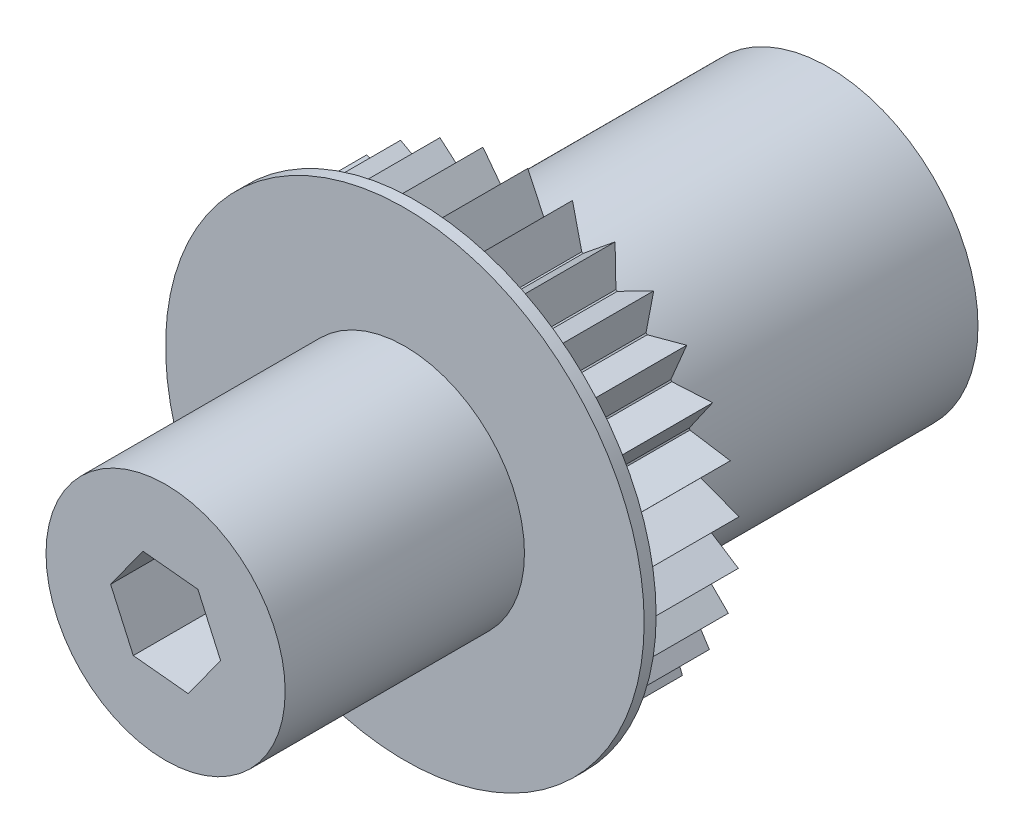
from build123d import *

# Parameters (mm, degrees)
SKETCH1_R               = 12.5
BOSS_EXTRUDE1_DEPTH     = 25.4
SKETCH2_R               = 9.9949
BOSS_EXTRUDE2_DEPTH     = 30
SKETCH4_R               = 15
BOSS_EXTRUDE3_DEPTH     = 10
SKETCH5_R               = 20
BOSS_EXTRUDE4_DEPTH     = 1
CUT_EXTRUDE1_DEPTH      = 1
CUT_EXTRUDE1_DEPTH_BACK = 56.4
CHAMFER1_SIZE           = 3


with BuildPart() as part:
    # Sketch1 → Boss-Extrude1 (new body)
    with BuildSketch(Plane.XY):
        Circle(SKETCH1_R)
    extrude(amount=BOSS_EXTRUDE1_DEPTH)

    # Sketch2 → Boss-Extrude2 (add)
    with BuildSketch(Plane.XY.offset(25.4)):
        Circle(SKETCH2_R)
    extrude(amount=BOSS_EXTRUDE2_DEPTH)

    # Sketch4 → Boss-Extrude3 (add)
    with BuildSketch(Plane.XY.offset(25.4)):
        Circle(SKETCH4_R)
        with BuildLine():
            ThreePointArc((-14.997117089, 0.294073132), (-14.892515339, 1.792480649), (-14.638580274, 3.272914233))
            Line((-14.638580274, 3.272914233), (-17.871018407, 2.150976779))
            Line((-17.871018407, 2.150976779), (-14.997117089, 0.294073132))
        make_face()
        with BuildLine():
            ThreePointArc((-14.730535341, -2.830429043), (-14.93975583, -1.343017399), (-14.999169305, 0.157861228))
            Line((-14.999169305, 0.157861228), (-17.927706996, -1.611620878))
            Line((-17.927706996, -1.611620878), (-14.730535341, -2.830429043))
        make_face()
        with BuildLine():
            ThreePointArc((-14.608252857, 3.4057229), (-14.194400465, 4.849638691), (-13.638215041, 6.24492518))
            Line((-13.638215041, 6.24492518), (-17.033280558, 5.819566429))
            Line((-17.033280558, 5.819566429), (-14.608252857, 3.4057229))
        make_face()
        with BuildLine():
            ThreePointArc((-13.580937876, 6.368526235), (-12.875922179, 7.694844251), (-12.041794367, 8.94400293))
            Line((-12.041794367, 8.94400293), (-15.451106615, 9.233813101))
            Line((-15.451106615, 9.233813101), (-13.580937876, 6.368526235))
        make_face()
        with BuildLine():
            ThreePointArc((-11.960070742, 9.052994413), (-10.994704308, 10.203748193), (-9.919089497, 11.252184835))
            Line((-9.919089497, 11.252184835), (-13.193645169, 12.244497832))
            Line((-13.193645169, 12.244497832), (-11.960070742, 9.052994413))
        make_face()
        with BuildLine():
            ThreePointArc((-9.816491125, 11.341803295), (-8.6329651, 12.266699376), (-7.362872818, 13.068592268))
            Line((-7.362872818, 13.068592268), (-10.35955812, 14.720039251))
            Line((-10.35955812, 14.720039251), (-9.816491125, 11.341803295))
        make_face()
        with BuildLine():
            ThreePointArc((-7.243883742, 13.134920949), (-5.893923892, 13.793536934), (-4.484863267, 14.313839509))
            Line((-4.484863267, 14.313839509), (-7.07270867, 16.552244321))
            Line((-7.07270867, 16.552244321), (-7.243883742, 13.134920949))
        make_face()
        with BuildLine():
            ThreePointArc((-4.354683879, 14.353979529), (-2.897289927, 14.71753074), (-1.41084367, 14.933503278))
            Line((-1.41084367, 14.933503278), (-3.476747913, 17.661036888))
            Line((-3.476747913, 17.661036888), (-4.354683879, 14.353979529))
        make_face()
        with BuildLine():
            Line((1.724836566, 14.900501294), (0.271163412, 17.997957395))
            Line((0.271163412, 17.997957395), (-1.275163434, 14.945700325))
            ThreePointArc((-1.275163434, 14.945700325), (0.22596951, 14.998297829), (1.724836566, 14.900501294))
        make_face()
        with BuildLine():
            Line((4.007223594, 17.548280801), (1.860087771, 14.8842223))
            ThreePointArc((1.860087771, 14.8842223), (3.339352995, 14.623567334), (4.785133167, 14.216275904))
            Line((4.785133167, 14.216275904), (4.007223594, 17.548280801))
        make_face()
        with BuildLine():
            Line((7.568148876, 16.331660129), (4.914044216, 14.172232338))
            ThreePointArc((4.914044216, 14.172232338), (6.30679073, 13.609716775), (7.636296486, 12.910731039))
            Line((7.636296486, 12.910731039), (7.568148876, 16.331660129))
        make_face()
        with BuildLine():
            Line((10.798309737, 14.401267542), (7.753233347, 12.840847817))
            ThreePointArc((7.753233347, 12.840847817), (8.998591447, 12.001056285), (10.153717007, 11.040925276))
            Line((10.153717007, 11.040925276), (10.798309737, 14.401267542))
        make_face()
        with BuildLine():
            Line((13.556532646, 11.841470459), (10.253568978, 10.948256629))
            ThreePointArc((10.253568978, 10.948256629), (11.297110538, 9.867892049), (12.227371371, 8.688578098))
            Line((12.227371371, 8.688578098), (13.556532646, 11.841470459))
        make_face()
        with BuildLine():
            Line((15.722270026, 8.764144294), (12.305774442, 8.577174091))
            ThreePointArc((12.305774442, 8.577174091), (13.101891689, 7.303453579), (13.766630933, 5.956498364))
            Line((13.766630933, 5.956498364), (15.722270026, 8.764144294))
        make_face()
        with BuildLine():
            Line((17.200868763, 5.303782969), (13.820158513, 5.831227887))
            ThreePointArc((13.820158513, 5.831227887), (14.334057303, 4.419819141), (14.704222663, 2.964091069))
            Line((14.704222663, 2.964091069), (17.200868763, 5.303782969))
        make_face()
        with BuildLine():
            Line((17.927706996, 1.611620878), (14.730535341, 2.830429043))
            ThreePointArc((14.730535341, 2.830429043), (14.932481879, 1.4216135), (15, 0))
            ThreePointArc((15, 0), (14.999792325, -0.078931707), (14.999169305, -0.157861228))
            Line((14.999169305, -0.157861228), (17.927706996, 1.611620878))
        make_face()
        with BuildLine():
            Line((17.871018407, -2.150976779), (14.997117089, -0.294073132))
            ThreePointArc((14.997117089, -0.294073132), (14.892515339, -1.792480649), (14.638580274, -3.272914233))
            Line((14.638580274, -3.272914233), (17.871018407, -2.150976779))
        make_face()
        with BuildLine():
            Line((17.033280558, -5.819566429), (14.608252857, -3.4057229))
            ThreePointArc((14.608252857, -3.4057229), (14.194400465, -4.849638691), (13.638215041, -6.24492518))
            Line((13.638215041, -6.24492518), (17.033280558, -5.819566429))
        make_face()
        with BuildLine():
            Line((15.451106615, -9.233813101), (13.580937876, -6.368526235))
            ThreePointArc((13.580937876, -6.368526235), (12.875922179, -7.694844251), (12.041794367, -8.94400293))
            Line((12.041794367, -8.94400293), (15.451106615, -9.233813101))
        make_face()
        with BuildLine():
            Line((13.193645169, -12.244497832), (11.960070742, -9.052994413))
            ThreePointArc((11.960070742, -9.052994413), (10.994704308, -10.203748193), (9.919089497, -11.252184835))
            Line((9.919089497, -11.252184835), (13.193645169, -12.244497832))
        make_face()
        with BuildLine():
            Line((10.35955812, -14.720039251), (9.816491125, -11.341803295))
            ThreePointArc((9.816491125, -11.341803295), (8.6329651, -12.266699376), (7.362872818, -13.068592268))
            Line((7.362872818, -13.068592268), (10.35955812, -14.720039251))
        make_face()
        with BuildLine():
            Line((7.07270867, -16.552244321), (7.243883742, -13.134920949))
            ThreePointArc((7.243883742, -13.134920949), (5.893923892, -13.793536934), (4.484863267, -14.313839509))
            Line((4.484863267, -14.313839509), (7.07270867, -16.552244321))
        make_face()
        with BuildLine():
            Line((3.476747913, -17.661036888), (4.354683879, -14.353979529))
            ThreePointArc((4.354683879, -14.353979529), (2.897289927, -14.71753074), (1.41084367, -14.933503278))
            Line((1.41084367, -14.933503278), (3.476747913, -17.661036888))
        make_face()
        with BuildLine():
            ThreePointArc((1.275163434, -14.945700325), (-0.22596951, -14.998297829), (-1.724836566, -14.900501294))
            Line((-1.724836566, -14.900501294), (-0.271163412, -17.997957395))
            Line((-0.271163412, -17.997957395), (1.275163434, -14.945700325))
        make_face()
        with BuildLine():
            ThreePointArc((-1.860087771, -14.8842223), (-3.339352995, -14.623567334), (-4.785133167, -14.216275904))
            Line((-4.785133167, -14.216275904), (-4.007223594, -17.548280801))
            Line((-4.007223594, -17.548280801), (-1.860087771, -14.8842223))
        make_face()
        with BuildLine():
            ThreePointArc((-4.914044216, -14.172232338), (-6.30679073, -13.609716775), (-7.636296486, -12.910731039))
            Line((-7.636296486, -12.910731039), (-7.568148876, -16.331660129))
            Line((-7.568148876, -16.331660129), (-4.914044216, -14.172232338))
        make_face()
        with BuildLine():
            ThreePointArc((-7.753233347, -12.840847817), (-8.998591447, -12.001056285), (-10.153717007, -11.040925276))
            Line((-10.153717007, -11.040925276), (-10.798309737, -14.401267542))
            Line((-10.798309737, -14.401267542), (-7.753233347, -12.840847817))
        make_face()
        with BuildLine():
            ThreePointArc((-10.253568978, -10.948256629), (-11.297110538, -9.867892049), (-12.227371371, -8.688578098))
            Line((-12.227371371, -8.688578098), (-13.556532646, -11.841470459))
            Line((-13.556532646, -11.841470459), (-10.253568978, -10.948256629))
        make_face()
        with BuildLine():
            ThreePointArc((-12.305774442, -8.577174091), (-13.101891689, -7.303453579), (-13.766630933, -5.956498364))
            Line((-13.766630933, -5.956498364), (-15.722270026, -8.764144294))
            Line((-15.722270026, -8.764144294), (-12.305774442, -8.577174091))
        make_face()
        with BuildLine():
            ThreePointArc((-13.820158513, -5.831227887), (-14.334057303, -4.419819141), (-14.704222663, -2.964091069))
            Line((-14.704222663, -2.964091069), (-17.200868763, -5.303782969))
            Line((-17.200868763, -5.303782969), (-13.820158513, -5.831227887))
        make_face()
    extrude(amount=BOSS_EXTRUDE3_DEPTH)

    # Sketch5 → Boss-Extrude4 (add)
    with BuildSketch(Plane.XY.offset(35.4)):
        Circle(SKETCH5_R)
    extrude(amount=-BOSS_EXTRUDE4_DEPTH)

    # Sketch3 → Cut-Extrude1 (cut, two sides)
    with BuildSketch(Plane(origin=(0, 0, 0), x_dir=(-1, 0, 0), z_dir=(0, 0, -1))) as cut_extrude1_sk:
        Polygon((1.896610387, 4.211437091), (-2.698906314, 3.748231322), (-4.595516701, -0.46320577), (-1.896610387, -4.211437091), (2.698906314, -3.748231322), (4.595516701, 0.46320577), align=None)
    extrude(amount=CUT_EXTRUDE1_DEPTH, mode=Mode.SUBTRACT)
    extrude(cut_extrude1_sk.sketch, amount=-CUT_EXTRUDE1_DEPTH_BACK, mode=Mode.SUBTRACT)

    # Chamfer1
    chamfer1_edges = [part.edges().sort_by_distance(p)[0] for p in [
        (-3.246063544, 2.337321431, 0),
        (-3.647211508, -1.642512776, 0),
        (-0.401147964, -3.979834206, 0),
        (3.246063544, -2.337321431, 0),
        (3.647211508, 1.642512776, 0),
        (0.401147964, 3.979834206, 0),
    ]]
    chamfer(chamfer1_edges, length=CHAMFER1_SIZE)


solid = part.part
